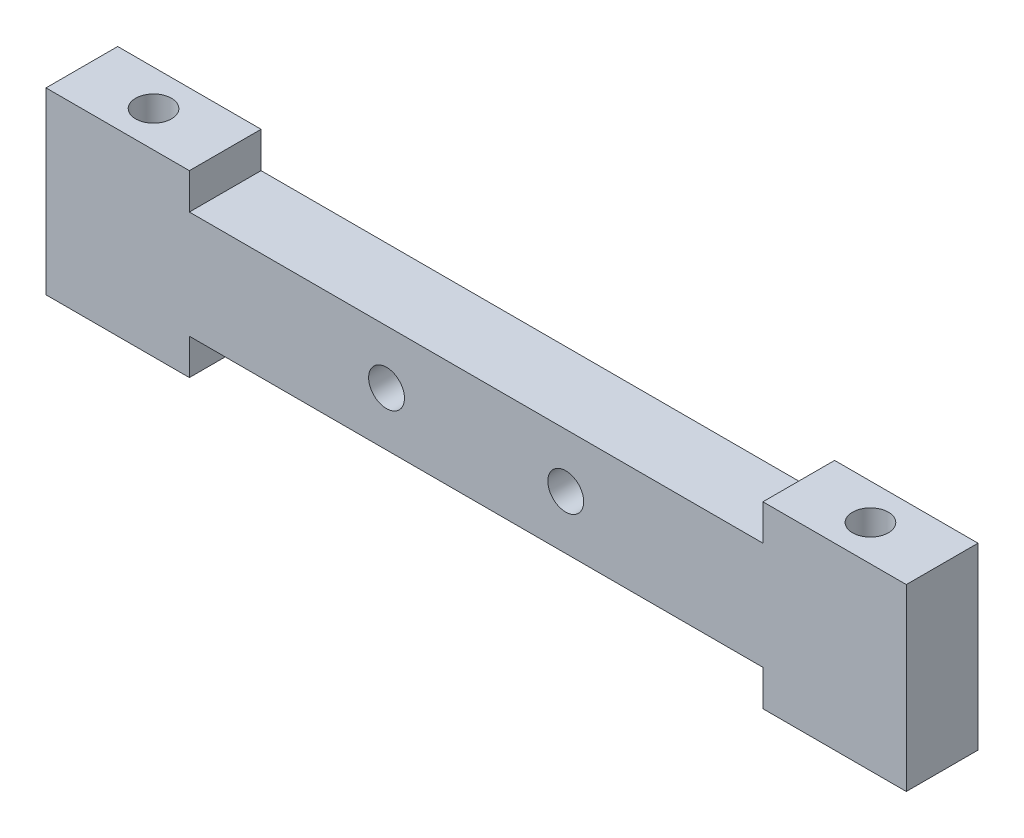
from build123d import *

# Parameters (mm, degrees)
ESQUISSE1_R             = 5
BOSS_EXTRU_2_DEPTH      = 10
ESQUISSE3_R             = 5
ENL_V_MAT_EXTRU_1_DEPTH = 51


with BuildPart() as part:
    # Esquisse1 → Boss.-Extru.2 (new body, symmetric)
    with BuildSketch(Plane.XY):
        Polygon((-119.537747133, 25), (-79.537747133, 25), (-79.537747133, 15), (80.462252867, 15), (80.462252867, 25), (120.462252867, 25), (120.462252867, -25), (80.462252867, -25), (80.462252867, -15), (-79.537747133, -15), (-79.537747133, -25), (-119.537747133, -25), align=None)
        with Locations((-24.537747133, 0)):
            Circle(ESQUISSE1_R, mode=Mode.SUBTRACT)
        with Locations((25.462252867, 0)):
            Circle(ESQUISSE1_R, mode=Mode.SUBTRACT)
    extrude(amount=BOSS_EXTRU_2_DEPTH, both=True)

    # Esquisse3 → Enlèv. mat.-Extru.1 (cut, through all)
    with BuildSketch(Plane(origin=(0, 25, 0), x_dir=(1, 0, 0), z_dir=(0, 1, 0))):
        with Locations(Location((-99.537747133, 0, 0), (0, 0, 180))):  # turned: the seam where the file's is
            Circle(ESQUISSE3_R)
        with Locations(Location((100.462252867, 0, 0), (0, 0, 180))):  # turned: the seam where the file's is
            Circle(ESQUISSE3_R)
    extrude(amount=-ENL_V_MAT_EXTRU_1_DEPTH, mode=Mode.SUBTRACT)


solid = part.part
